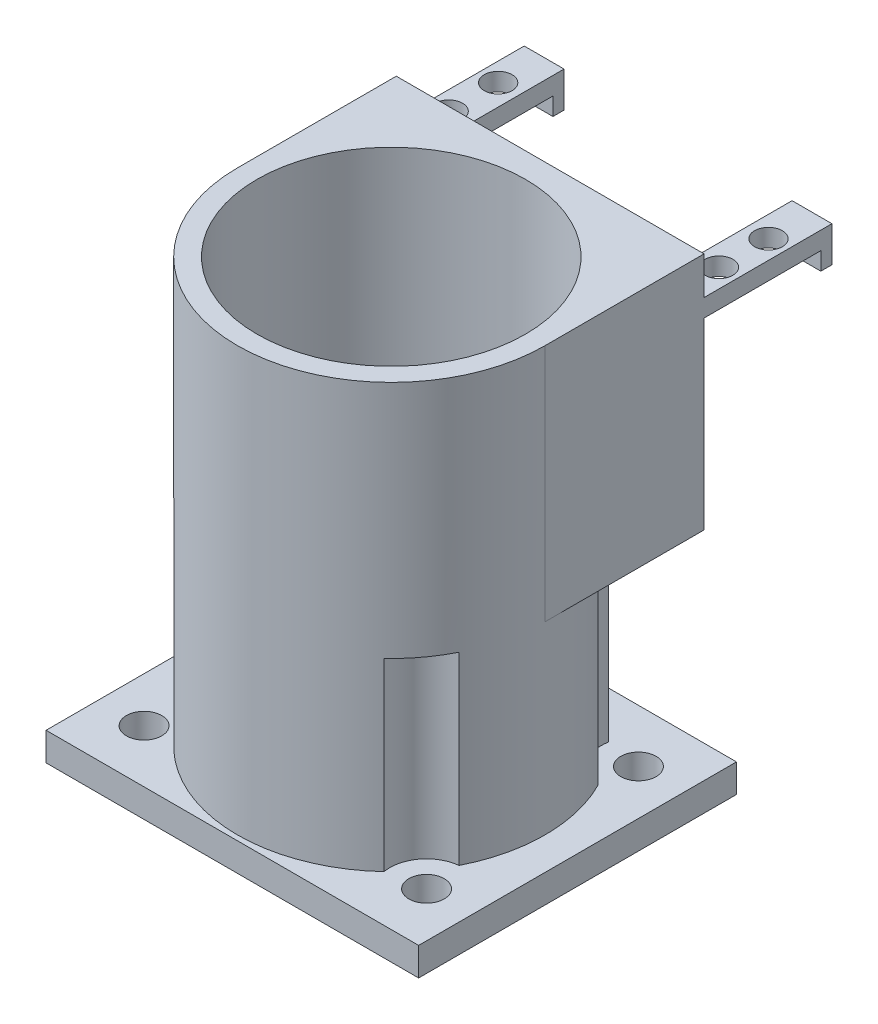
from build123d import *

# Parameters (mm, degrees)
SKETCH1_W           = 67
SKETCH1_H           = 57.15
SKETCH1_R           = 3.175
BOSS_EXTRUDE1_DEPTH = 5.08
SKETCH2_R           = 27.67
SKETCH2_R_2         = 24.13
BOSS_EXTRUDE2_DEPTH = 76.2
BOSS_EXTRUDE3_REACH = 59.15
SKETCH4_W           = 55.34
SKETCH4_H           = 43
SKETCH5_W           = 7.17
SKETCH5_H           = 3.2
BOSS_EXTRUDE4_DEPTH = 21
SKETCH6_R           = 2.5
CUT_EXTRUDE1_DEPTH  = 11
SKETCH7_W           = 7.17
SKETCH7_H           = 3.2
BOSS_EXTRUDE5_DEPTH = 2
SKETCH8_W           = 7.17
SKETCH8_H           = 2
BOSS_EXTRUDE6_DEPTH = 3.2
SKETCH9_R           = 6.6
CUT_EXTRUDE2_DEPTH  = 33.2


with BuildPart() as part:
    # Sketch1 → Boss-Extrude1 (new body)
    with BuildSketch(Plane(origin=(0, 0, 0), x_dir=(1, 0, 0), z_dir=(0, 1, 0))):
        with Locations((33.5, -28.575)):
            Rectangle(SKETCH1_W, SKETCH1_H)
        with Locations((8.1, -9.525)):
            Circle(SKETCH1_R, mode=Mode.SUBTRACT)
        with Locations((58.9, -9.525)):
            Circle(SKETCH1_R, mode=Mode.SUBTRACT)
        with Locations((58.9, -47.625)):
            Circle(SKETCH1_R, mode=Mode.SUBTRACT)
        with Locations((8.1, -47.625)):
            Circle(SKETCH1_R, mode=Mode.SUBTRACT)
    extrude(amount=BOSS_EXTRUDE1_DEPTH)

    # Sketch2 → Boss-Extrude2 (add)
    with BuildSketch(Plane(origin=(0, 5.08, 0), x_dir=(1, 0, 0), z_dir=(0, 1, 0))):
        with Locations((33.5, -28.575)):
            Circle(SKETCH2_R)
        with Locations((33.5, -28.575)):
            Circle(SKETCH2_R_2, mode=Mode.SUBTRACT)
    extrude(amount=BOSS_EXTRUDE2_DEPTH)

    # Sketch4 → Boss-Extrude3 (add, up to next)
    with BuildSketch(Plane(origin=(0, 0, 0), x_dir=(-1, 0, 0), z_dir=(0, 0, -1)), mode=Mode.PRIVATE) as boss_extrude3_sk1:
        with Locations((-33.5, 59.78)):
            Rectangle(SKETCH4_W, SKETCH4_H)
    boss_extrude3_tool1 = extrude(boss_extrude3_sk1.sketch, amount=-BOSS_EXTRUDE3_REACH, mode=Mode.PRIVATE) - part.part
    add(boss_extrude3_tool1.solids().sort_by_distance((33.5, 59.78, 0))[0])

    # Sketch5 → Boss-Extrude4 (add)
    with BuildSketch(Plane(origin=(0, 0, 0), x_dir=(-1, 0, 0), z_dir=(0, 0, -1))):
        with Locations((-9.415, 72.88)):
            Rectangle(SKETCH5_W, SKETCH5_H)
        with Locations((-57.585, 72.88)):
            Rectangle(SKETCH5_W, SKETCH5_H)
    extrude(amount=BOSS_EXTRUDE4_DEPTH)

    # Sketch6 → Cut-Extrude1 (cut, through all)
    with BuildSketch(Plane.XZ.offset(-71.28)):
        with Locations((9.2, -6.05)):
            Circle(SKETCH6_R)
        with Locations((57.8, -6.05)):
            Circle(SKETCH6_R)
        with Locations((57.8, -14.95)):
            Circle(SKETCH6_R)
        with Locations((9.2, -14.95)):
            Circle(SKETCH6_R)
    extrude(amount=-CUT_EXTRUDE1_DEPTH, mode=Mode.SUBTRACT)

    # Sketch7 → Boss-Extrude5 (add)
    with BuildSketch(Plane(origin=(0, 0, -21), x_dir=(-1, 0, 0), z_dir=(0, 0, -1))):
        with Locations((-57.585, 72.88)):
            Rectangle(SKETCH7_W, SKETCH7_H)
        with Locations((-9.415, 72.88)):
            Rectangle(SKETCH7_W, SKETCH7_H)
    extrude(amount=BOSS_EXTRUDE5_DEPTH)

    # Sketch8 → Boss-Extrude6 (add)
    with BuildSketch(Plane.XZ.offset(-71.28)):
        with Locations((9.415, -22)):
            Rectangle(SKETCH8_W, SKETCH8_H)
        with Locations((57.585, -22)):
            Rectangle(SKETCH8_W, SKETCH8_H)
    extrude(amount=BOSS_EXTRUDE6_DEPTH)

    # Sketch9 → Cut-Extrude2 (cut)
    with BuildSketch(Plane(origin=(0, 5.08, 0), x_dir=(1, 0, 0), z_dir=(0, 1, 0))):
        with Locations((8.1, -9.525)):
            Circle(SKETCH9_R)
        with Locations((58.9, -9.525)):
            Circle(SKETCH9_R)
        with Locations((58.9, -47.625)):
            Circle(SKETCH9_R)
        with Locations((8.1, -47.625)):
            Circle(SKETCH9_R)
    extrude(amount=CUT_EXTRUDE2_DEPTH, mode=Mode.SUBTRACT)


solid = part.part
